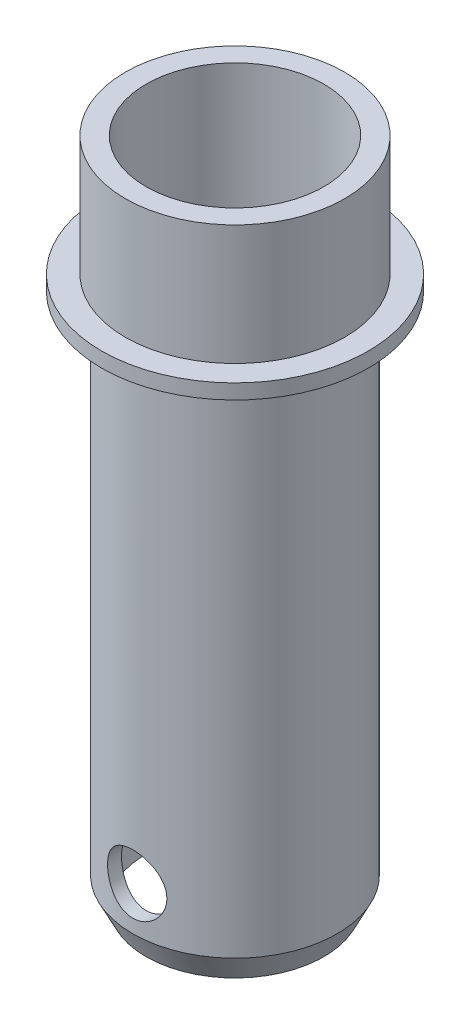
from build123d import *

# Parameters (mm, degrees)
SKETCH_2_R               = 2
CUT_EXTRUDE_1_DEPTH      = 10
CUT_EXTRUDE_1_DEPTH_BACK = 10


with BuildPart() as part:
    # Эскиз1 → Повернуть1 (revolve)
    with BuildSketch(Plane.XY, mode=Mode.PRIVATE) as revolve_1_sk:
        Polygon((-7.4, 9.1), (-7.4, 1), (-9, 1), (-9, 0), (-6.894121554, 0), (-6.894121554, -34.110992832), (-6, -35.9), (-6, 9.1), align=None)
    revolve(revolve_1_sk.sketch.rotate(Axis((0, 30.712290503, 0), (0, -1, 0)), 270), axis=Axis((0, 30.712290503, 0), (0, -1, 0)))  # turned: the seam where the file's is

    # Эскиз2 → Вырез-Вытянуть1 (cut, two sides)
    with BuildSketch(Plane.XY) as cut_extrude_1_sk:
        with Locations((0, -31.2)):
            Circle(SKETCH_2_R)
    extrude(amount=CUT_EXTRUDE_1_DEPTH, mode=Mode.SUBTRACT)
    extrude(cut_extrude_1_sk.sketch, amount=-CUT_EXTRUDE_1_DEPTH_BACK, mode=Mode.SUBTRACT)


solid = part.part
